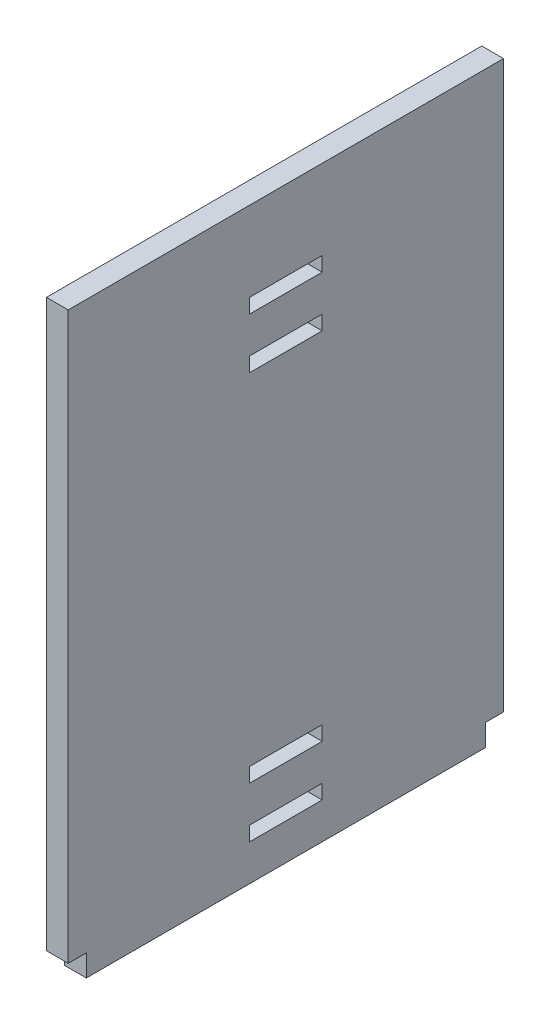
from build123d import *

# Parameters (mm, degrees)
CROQUIS2_W              = 135
CROQUIS2_H              = 162
SALIENTE_EXTRUIR1_DEPTH = 6
CROQUIS4_W              = 6
CROQUIS4_H              = 13.5
CROQUIS4_H_2            = 1.5
CORTAR_EXTRUIR2_DEPTH   = 163
CROQUIS5_W              = 6
CROQUIS5_H              = 6.5
CROQUIS5_H_2            = 5
CORTAR_EXTRUIR3_DEPTH   = 6
CROQUIS7_W              = 20
CROQUIS7_H              = 4
CORTAR_EXTRUIR5_DEPTH   = 6


with BuildPart() as part:
    # Croquis2 → Saliente-Extruir1 (new body)
    with BuildSketch(Plane(origin=(0, 0, 0), x_dir=(0, 0, -1), z_dir=(1, 0, 0))):
        Rectangle(CROQUIS2_W, CROQUIS2_H)
    extrude(amount=SALIENTE_EXTRUIR1_DEPTH)

    # Croquis4 → Cortar-Extruir2 (cut, through all)
    with BuildSketch(Plane(origin=(0, 81, 0), x_dir=(1, 0, 0), z_dir=(0, 1, 0))):
        with Locations((3, 60.75)):
            Rectangle(CROQUIS4_W, CROQUIS4_H)
        with Locations((3, -66.75)):
            Rectangle(CROQUIS4_W, CROQUIS4_H_2)
    extrude(amount=-CORTAR_EXTRUIR2_DEPTH, mode=Mode.SUBTRACT)

    # Croquis5 → Cortar-Extruir3 (cut)
    with BuildSketch(Plane.XZ.offset(81)):
        with Locations((3, 64.25)):
            Rectangle(CROQUIS5_W, CROQUIS5_H)
        with Locations((3, -51.5)):
            Rectangle(CROQUIS5_W, CROQUIS5_H_2)
    extrude(amount=-CORTAR_EXTRUIR3_DEPTH, mode=Mode.SUBTRACT)

    # Croquis7 → Cortar-Extruir5 (cut)
    with BuildSketch(Plane(origin=(6, 0, 0), x_dir=(0, 0, -1), z_dir=(1, 0, 0))):
        with Locations((-6, -69)):
            Rectangle(CROQUIS7_W, CROQUIS7_H)
        with Locations((-6, -55)):
            Rectangle(CROQUIS7_W, CROQUIS7_H)
        with Locations((-6, 43)):
            Rectangle(CROQUIS7_W, CROQUIS7_H)
        with Locations((-6, 57)):
            Rectangle(CROQUIS7_W, CROQUIS7_H)
    extrude(amount=-CORTAR_EXTRUIR5_DEPTH, mode=Mode.SUBTRACT)


solid = part.part
